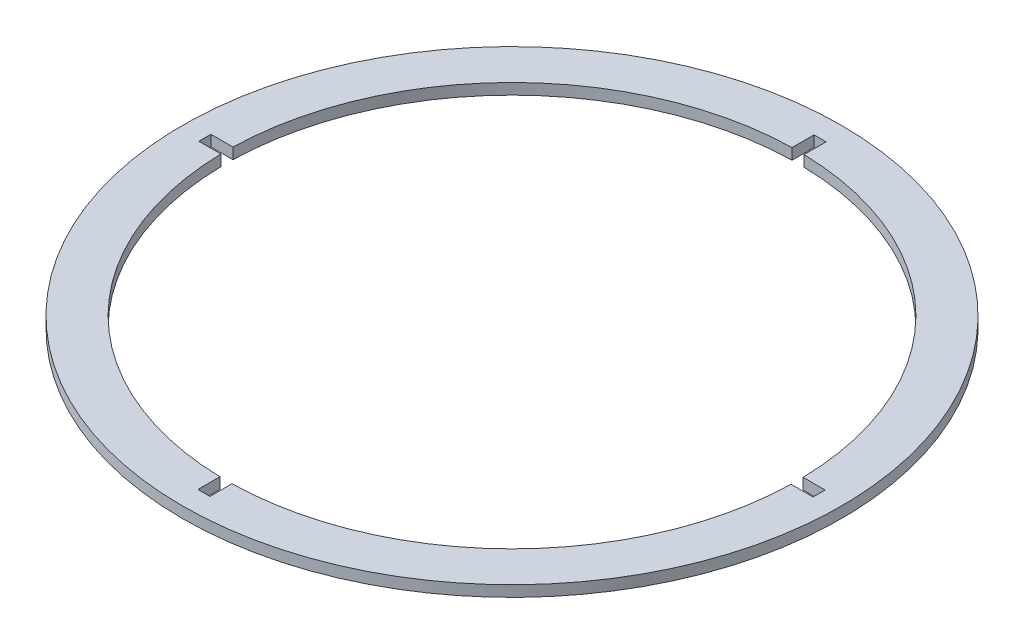
from build123d import *

# Parameters (mm, degrees)
SKETCH1_R           = 150
BOSS_EXTRUDE1_DEPTH = 2.5


with BuildPart() as part:
    # Sketch1 → Boss-Extrude1 (new body, symmetric)
    with BuildSketch(Plane(origin=(0, 0, 0), x_dir=(1, 0, 0), z_dir=(0, 1, 0))):
        Circle(SKETCH1_R)
        with BuildLine():
            Line((2.525, -129.975476052), (2.525, -140))
            Line((2.525, -140), (-2.975, -140))
            Line((-2.975, -140), (-2.975, -129.965954677))
            ThreePointArc((-2.975, -129.965954677), (-92.082878446, -91.764609176), (-129.975476052, -2.525))
            Line((-129.975476052, -2.525), (-140, -2.525))
            Line((-140, -2.525), (-140, 2.975))
            Line((-140, 2.975), (-129.965954677, 2.975))
            ThreePointArc((-129.965954677, 2.975), (-91.764609176, 92.082878446), (-2.525, 129.975476052))
            Line((-2.525, 129.975476052), (-2.525, 140))
            Line((-2.525, 140), (2.975, 140))
            Line((2.975, 140), (2.975, 129.965954677))
            ThreePointArc((2.975, 129.965954677), (92.082878446, 91.764609176), (129.975476052, 2.525))
            Line((129.975476052, 2.525), (140, 2.525))
            Line((140, 2.525), (140, -2.975))
            Line((140, -2.975), (129.965954677, -2.975))
            ThreePointArc((129.965954677, -2.975), (91.764609176, -92.082878446), (2.525, -129.975476052))
        make_face(mode=Mode.SUBTRACT)
    extrude(amount=BOSS_EXTRUDE1_DEPTH, both=True)


solid = part.part
